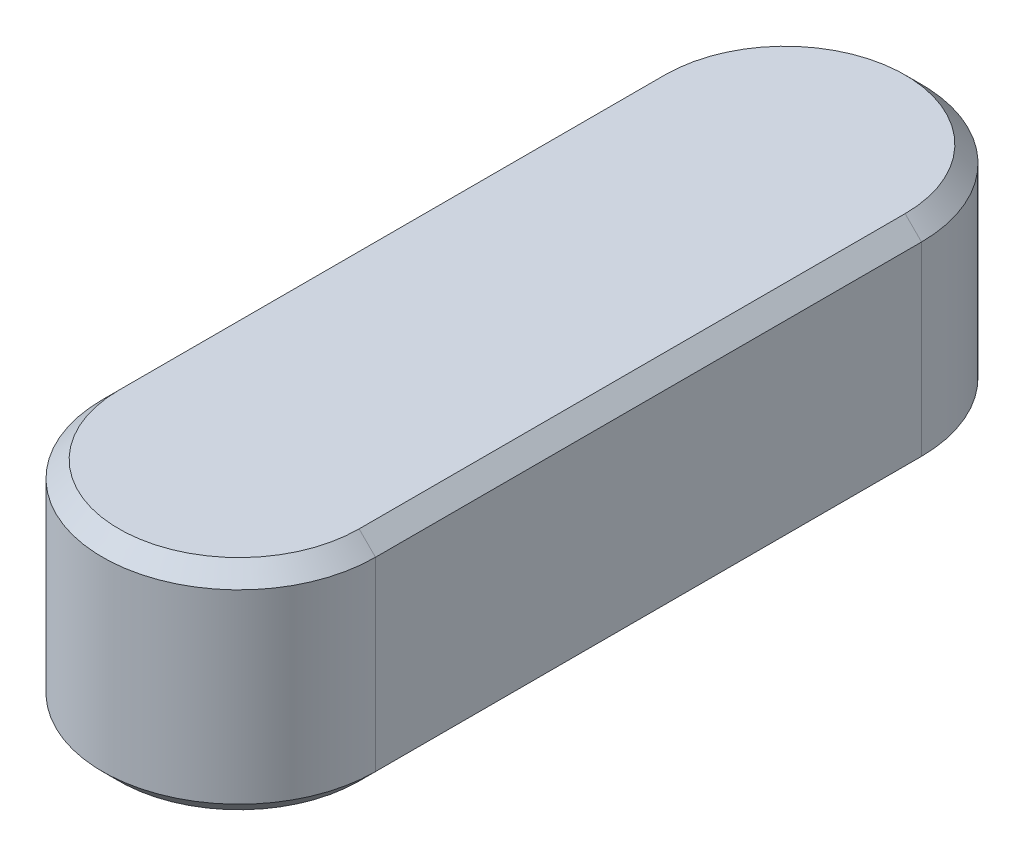
from build123d import *

# Parameters (mm, degrees)
BOSS_EXTRUDE1_DEPTH = 8
CHAMFER1_SIZE       = 0.6


with BuildPart() as part:
    # Sketch1 → Boss-Extrude1 (new body)
    with BuildSketch(Plane(origin=(0, 0, 0), x_dir=(1, 0, 0), z_dir=(0, 1, 0))):
        with BuildLine():
            Line((5, 0), (5, 20))
            ThreePointArc((5, 20), (0, 25), (-5, 20))
            Line((-5, 20), (-5, 0))
            ThreePointArc((-5, 0), (0, -5), (5, 0))
        make_face()
    extrude(amount=BOSS_EXTRUDE1_DEPTH)

    # Chamfer1
    chamfer1_edges = [part.edges().sort_by_distance(p)[0] for p in [
        (0, 8, -25),
        (-5, 8, -10),
        (0, 8, 5),
        (-5, 0, -10),
        (0, 0, -25),
        (5, 0, -10),
        (0, 0, 5),
        (5, 8, -10),
    ]]
    chamfer(chamfer1_edges, length=CHAMFER1_SIZE)


solid = part.part
